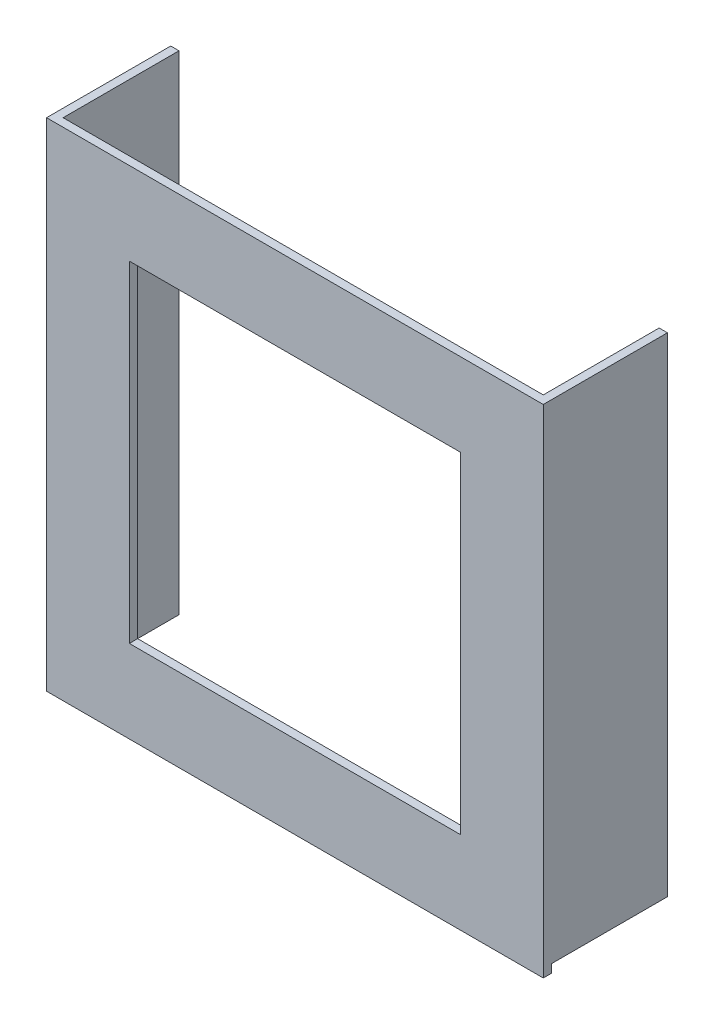
from build123d import *

# Parameters (mm, degrees)
SKETCH1_W           = 300
SKETCH1_H           = 300
SKETCH1_W_2         = 200
SKETCH1_H_2         = 200
BOSS_EXTRUDE1_DEPTH = 5
BOSS_EXTRUDE5_DEPTH = 70


with BuildPart() as part:
    # Sketch1 → Boss-Extrude1 (new body)
    with BuildSketch(Plane.XY):
        Rectangle(SKETCH1_W, SKETCH1_H)
        Rectangle(SKETCH1_W_2, SKETCH1_H_2, mode=Mode.SUBTRACT)
    extrude(amount=BOSS_EXTRUDE1_DEPTH)

    # Sketch2 → Boss-Extrude5 (add)
    with BuildSketch(Plane(origin=(0, 0, 0), x_dir=(-1, 0, 0), z_dir=(0, 0, -1))):
        Polygon((-150, -145), (-145, -145), (-145, 145), (-145, 150), (-150, 150), align=None)
        Polygon((145, 145), (145, -145), (150, -145), (150, 150), (145, 150), align=None)
    extrude(amount=BOSS_EXTRUDE5_DEPTH)


solid = part.part
